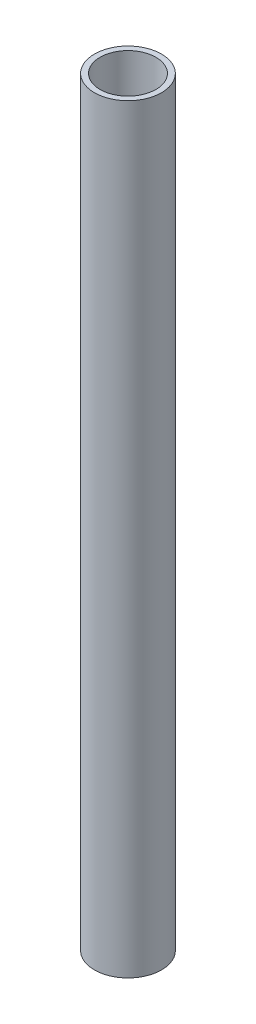
from build123d import *

# Parameters (mm, degrees)
SKETCH2_R           = 19.05
SKETCH2_R_2         = 15.875
BOSS_EXTRUDE1_DEPTH = 431.8


with BuildPart() as part:
    # Sketch2 → Boss-Extrude1 (new body)
    with BuildSketch(Plane(origin=(0, 0, 0), x_dir=(1, 0, 0), z_dir=(0, 1, 0))):
        Circle(SKETCH2_R)
        Circle(SKETCH2_R_2, mode=Mode.SUBTRACT)
    extrude(amount=BOSS_EXTRUDE1_DEPTH)


solid = part.part
